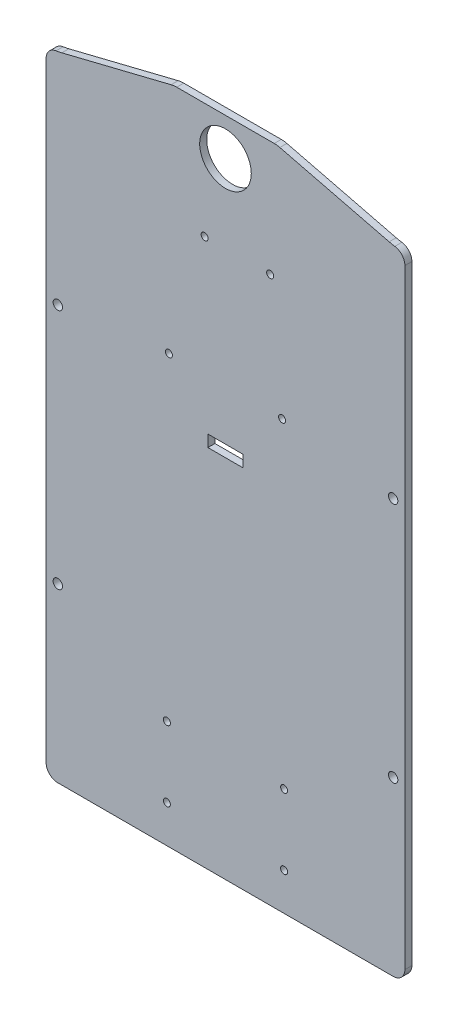
from build123d import *

# Parameters (mm, degrees)
CROQUIS1_W              = 153
CROQUIS1_H              = 270
SALIENTE_EXTRUIR1_DEPTH = 3
CROQUIS2_R              = 2
CORTAR_EXTRUIR1_DEPTH   = 4
REDONDEO1_R             = 5
SALIENTE_EXTRUIR2_DEPTH = 3
REDONDEO2_R             = 25
REDONDEO3_R             = 10
CROQUIS5_R              = 11
CORTAR_EXTRUIR3_DEPTH   = 4
CROQUIS6_R              = 1.5
CROQUIS6_W              = 15
CROQUIS6_H              = 5
CORTAR_EXTRUIR4_DEPTH   = 4
CROQUIS7_R              = 1.5
CORTAR_EXTRUIR5_DEPTH   = 10


with BuildPart() as part:
    # Croquis1 → Saliente-Extruir1 (new body)
    with BuildSketch(Plane.XY):
        Rectangle(CROQUIS1_W, CROQUIS1_H)
    extrude(amount=SALIENTE_EXTRUIR1_DEPTH)

    # Croquis2 → Cortar-Extruir1 (cut, through all)
    with BuildSketch(Plane.XY.offset(3)):
        with Locations((-71.5, 41.5)):
            Circle(CROQUIS2_R)
        with Locations((-71.5, -61.5)):
            Circle(CROQUIS2_R)
        with Locations((71.5, -61.5)):
            Circle(CROQUIS2_R)
        with Locations((71.5, 41.5)):
            Circle(CROQUIS2_R)
    extrude(amount=-CORTAR_EXTRUIR1_DEPTH, mode=Mode.SUBTRACT)

    # Redondeo1
    redondeo1_edges = [part.edges().sort_by_distance(p)[0] for p in [
        (76.5, -135, 1.5),
        (-76.5, -135, 1.5),
        (-76.5, 135, 1.5),
        (76.5, 135, 1.5),
    ]]
    fillet(redondeo1_edges, radius=REDONDEO1_R)

    # Croquis4 → Saliente-Extruir2 (add)
    with BuildSketch(Plane.XY.offset(3)):
        Polygon((22, 147.2375), (-22, 147.2375), (-71.5, 135), (71.5, 135), align=None)
    extrude(amount=-SALIENTE_EXTRUIR2_DEPTH)

    # Redondeo2
    redondeo2_edges = [part.edges().sort_by_distance(p)[0] for p in [
        (-71.5, 135, 1.5),
        (71.5, 135, 1.5),
    ]]
    fillet(redondeo2_edges, radius=REDONDEO2_R)

    # Redondeo3
    redondeo3_edges = [part.edges().sort_by_distance(p)[0] for p in [
        (22, 147.2375, 1.5),
        (-22, 147.2375, 1.5),
    ]]
    fillet(redondeo3_edges, radius=REDONDEO3_R)

    # Croquis5 → Cortar-Extruir3 (cut, through all)
    with BuildSketch(Plane.XY.offset(3)):
        with Locations((0, 131.2375)):
            Circle(CROQUIS5_R)
    extrude(amount=-CORTAR_EXTRUIR3_DEPTH, mode=Mode.SUBTRACT)

    # Croquis6 → Cortar-Extruir4 (cut, through all)
    with BuildSketch(Plane.XY.offset(3)):
        with Locations((-8.89, 98.0200592)):
            Circle(CROQUIS6_R)
        with Locations((19.05, 98.0200592)):
            Circle(CROQUIS6_R)
        with Locations((24.13, 47.2200592)):
            Circle(CROQUIS6_R)
        with Locations((-24.13, 47.2200592)):
            Circle(CROQUIS6_R)
        with Locations((0, 23.297668012)):
            Rectangle(CROQUIS6_W, CROQUIS6_H)
    extrude(amount=-CORTAR_EXTRUIR4_DEPTH, mode=Mode.SUBTRACT)

    # Croquis7 → Cortar-Extruir5 (cut)
    with BuildSketch(Plane.XY.offset(3)):
        with Locations((-25, -89.038395192)):
            Circle(CROQUIS7_R)
        with Locations((25, -89.038395192)):
            Circle(CROQUIS7_R)
        with Locations((-25, -119.038395192)):
            Circle(CROQUIS7_R)
        with Locations((25, -119.038395192)):
            Circle(CROQUIS7_R)
    extrude(amount=-CORTAR_EXTRUIR5_DEPTH, mode=Mode.SUBTRACT)


solid = part.part
